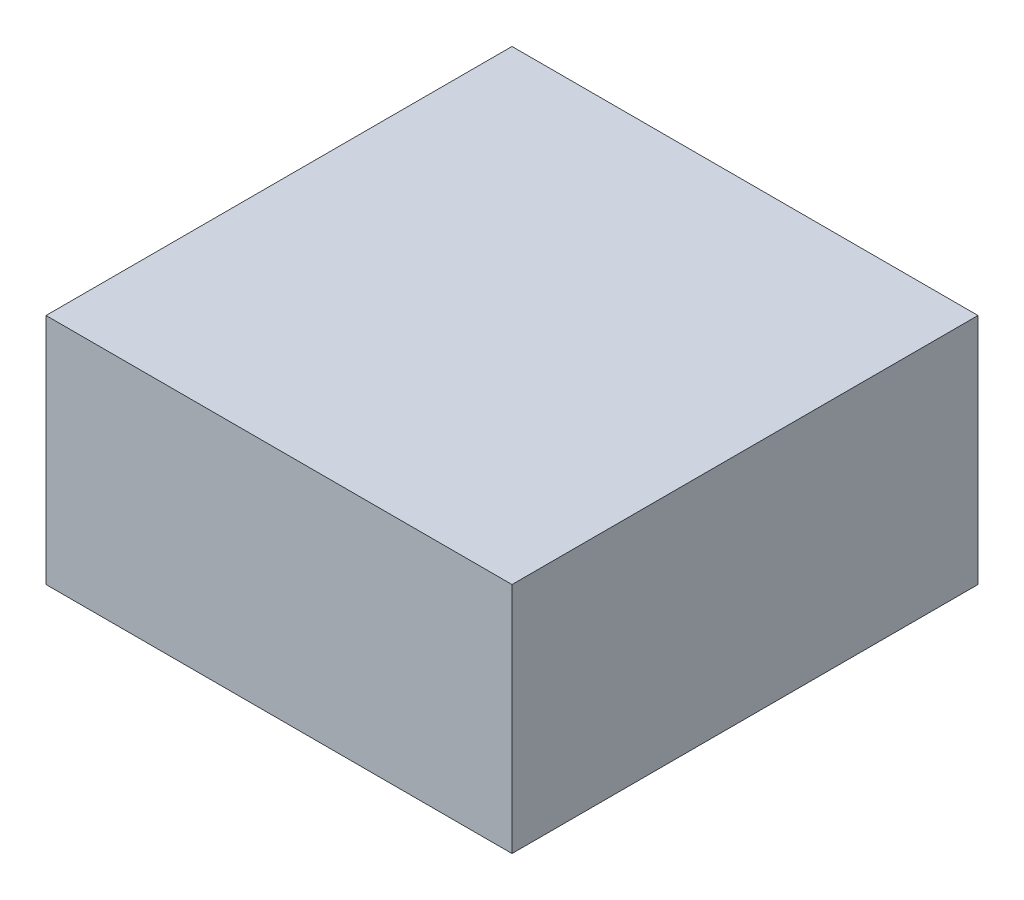
from build123d import *

# Parameters (mm, degrees)
SKETCH1_W           = 200
SKETCH1_H           = 100
BOSS_EXTRUDE1_DEPTH = 200


with BuildPart() as part:
    # Sketch1 → Boss-Extrude1 (new body)
    with BuildSketch(Plane.XY):
        Rectangle(SKETCH1_W, SKETCH1_H)
    extrude(amount=BOSS_EXTRUDE1_DEPTH)


solid = part.part
